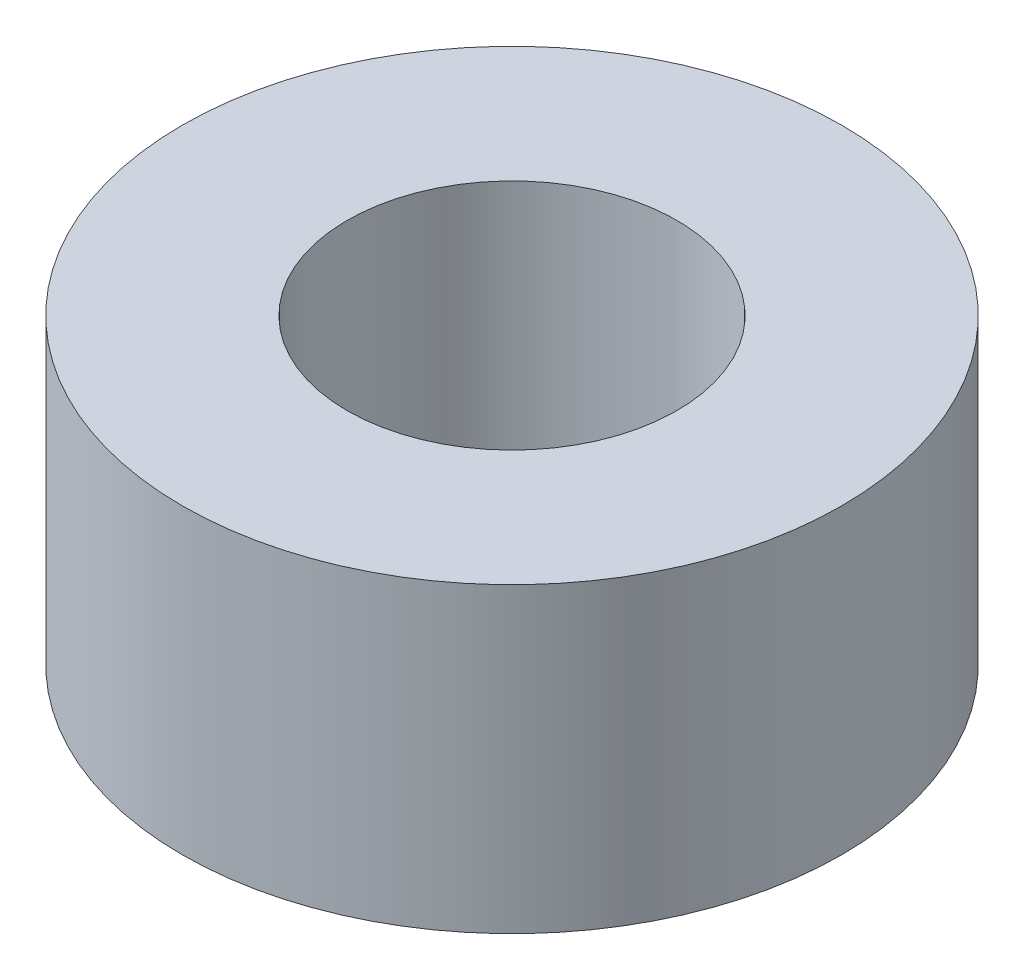
from build123d import *

# Parameters (mm, degrees)
SKETCH_1_R      = 6
SKETCH_1_R_2    = 3
EXTRUDE_1_DEPTH = 5.5


with BuildPart() as part:
    # 스케치1 → 보스-돌출1 (new body)
    with BuildSketch(Plane(origin=(0, 0, 0), x_dir=(1, 0, 0), z_dir=(0, 1, 0))):
        Circle(SKETCH_1_R)
        Circle(SKETCH_1_R_2, mode=Mode.SUBTRACT)
    extrude(amount=EXTRUDE_1_DEPTH)


solid = part.part
